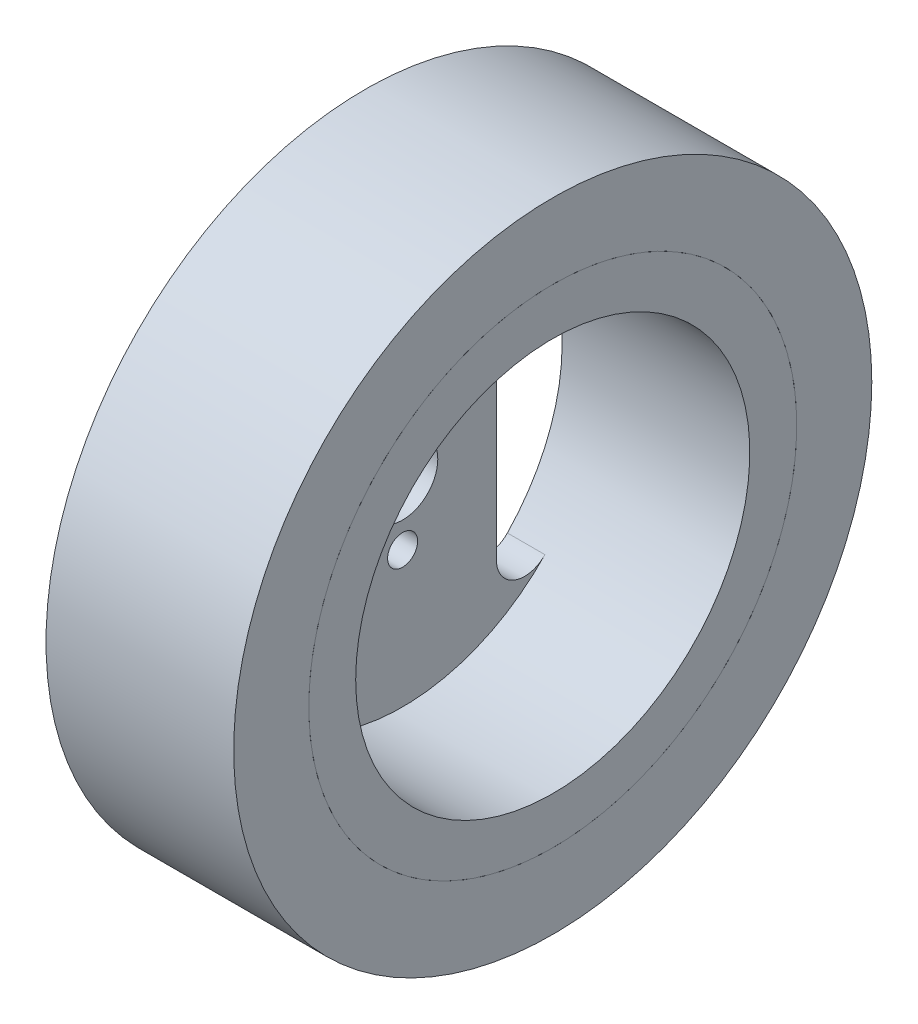
from build123d import *

# Parameters (mm, degrees)
SKETCH_2_R          = 3.75
SKETCH_2_R_2        = 1.6
CUT_EXTRUDE_1_DEPTH = 10
SKETCH_3_R          = 34
SKETCH_3_R_2        = 26
EXTRUDE_1_DEPTH     = 20


with BuildPart() as part:
    # 草图1 → 旋转1 (revolve)
    with BuildSketch(Plane.XY):
        Polygon((0, 0), (0, 26), (20, 26), (20, 21), (4, 21), (4, 0), align=None)
    revolve(axis=Axis((0, 0, 0), (1, 0, 0)))

    # 草图2 → 切除-拉伸1 (cut)
    with BuildSketch(Plane(origin=(4, 0, 0), x_dir=(0, 0, -1), z_dir=(1, 0, 0))):
        Circle(SKETCH_2_R)
        with Locations((0, 6.5)):
            Circle(SKETCH_2_R_2)
        with Locations((0, -6.5)):
            Circle(SKETCH_2_R_2)
        with BuildLine():
            Line((-10, 12.449899598), (-10, -12.449899598))
            ThreePointArc((-10, -12.449899598), (-11.881966011, -15.233781779), (-15.166666667, -14.524882864))
            ThreePointArc((-15.166666667, -14.524882864), (-21, 0), (-15.166666667, 14.524882864))
            ThreePointArc((-15.166666667, 14.524882864), (-11.881966011, 15.233781779), (-10, 12.449899598))
        make_face()
        with BuildLine():
            Line((10, 12.449899598), (10, -12.449899598))
            ThreePointArc((10, -12.449899598), (11.881966011, -15.233781779), (15.166666667, -14.524882864))
            ThreePointArc((15.166666667, -14.524882864), (21, 0), (15.166666667, 14.524882864))
            ThreePointArc((15.166666667, 14.524882864), (11.881966011, 15.233781779), (10, 12.449899598))
        make_face()
    extrude(amount=-CUT_EXTRUDE_1_DEPTH, mode=Mode.SUBTRACT)


with BuildPart() as body_2:
    # 草图3 → 凸台-拉伸1 (new body)
    with BuildSketch(Plane(origin=(20, 0, 0), x_dir=(0, 0, -1), z_dir=(1, 0, 0))):
        Circle(SKETCH_3_R)
        Circle(SKETCH_3_R_2, mode=Mode.SUBTRACT)
    extrude(amount=-EXTRUDE_1_DEPTH)


solid = Compound([part.part, body_2.part])
